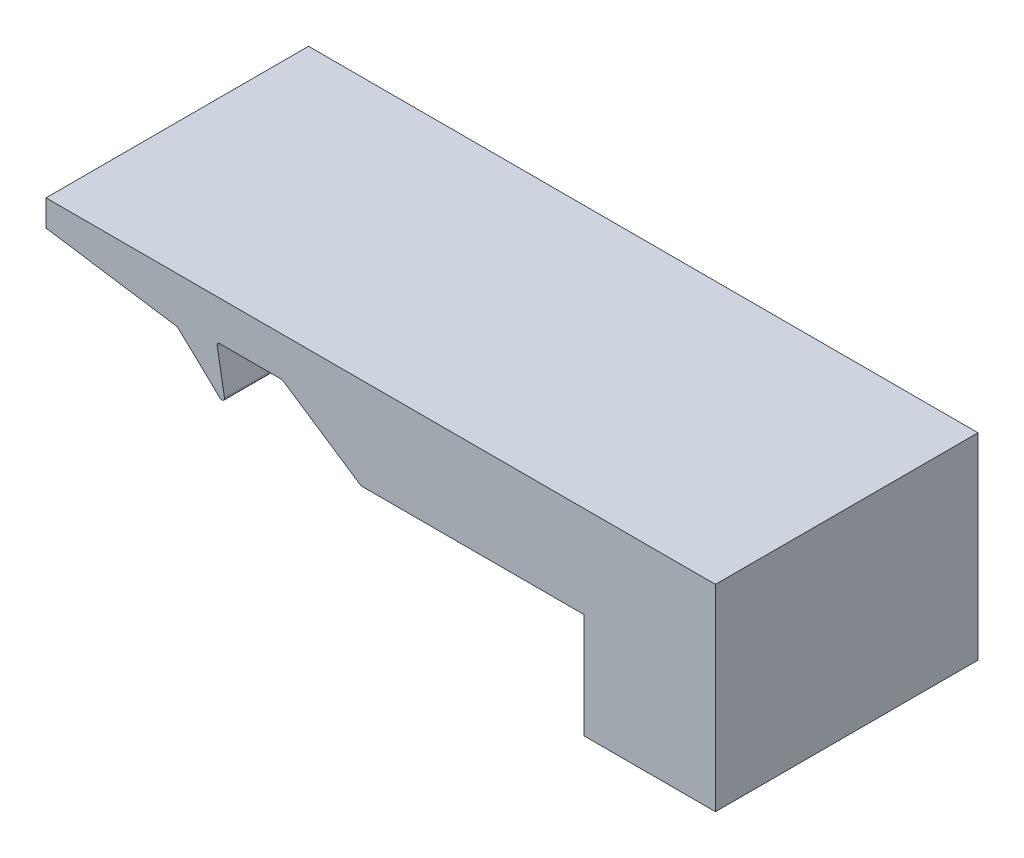
from build123d import *

# Parameters (mm, degrees)
BOSS_EXTRUDE1_DEPTH = 10
FILLET1_R           = 0.1


with BuildPart() as part:
    # Sketch1 → Boss-Extrude1 (new body)
    with BuildSketch(Plane.XY):
        Polygon((-17.64487365, -3.096839142), (-22.64487365, -3.096839142), (-22.64487365, 0.903160858), (-31.14487365, 0.903160858), (-34.14487365, 2.903160858), (-36.64487365, 2.903160858), (-36.294355732, 0.903160858), (-38.14487365, 2.653160858), (-43.14487365, 3.403160858), (-43.14487365, 4.403160858), (-17.64487365, 4.403160858), align=None)
    extrude(amount=BOSS_EXTRUDE1_DEPTH)

    # Fillet1
    fillet1_edges = [part.edges().sort_by_distance(p)[0] for p in [
        (-34.14487365, 2.903160858, 5),
        (-36.64487365, 2.903160858, 5),
        (-36.294355732, 0.903160858, 5),
    ]]
    fillet(fillet1_edges, radius=FILLET1_R)


solid = part.part
